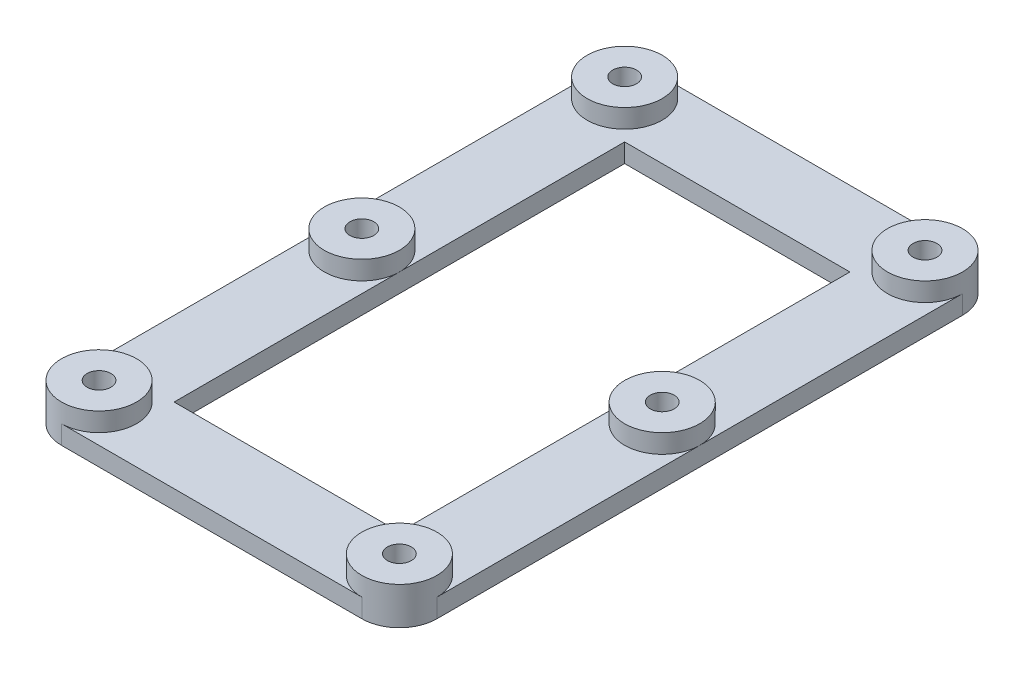
from build123d import *

# Parameters (mm, degrees)
SKETCH1_W              = 63.5
SKETCH1_H              = 101.6
BOSS_EXTRUDE1_DEPTH    = 6.35
FILLET1_R              = 6.35
F_10_32_TAPPED_HOLE1_D = 4.0386
SKETCH10_W             = 38.1
SKETCH10_H             = 76.2
CUT_EXTRUDE1_DEPTH     = 7.35
CUT_EXTRUDE2_DEPTH     = 3.175


with BuildPart() as part:
    # Sketch1 → Boss-Extrude1 (new body)
    with BuildSketch(Plane(origin=(0, 0, 0), x_dir=(1, 0, 0), z_dir=(0, 1, 0))):
        Rectangle(SKETCH1_W, SKETCH1_H)
    extrude(amount=BOSS_EXTRUDE1_DEPTH)

    # Fillet1
    fillet1_edges = [part.edges().sort_by_distance(p)[0] for p in [
        (-31.75, 3.175, -50.8),
        (31.75, 3.175, -50.8),
        (31.75, 3.175, 50.8),
        (-31.75, 3.175, 50.8),
    ]]
    fillet(fillet1_edges, radius=FILLET1_R)

    # #10-32 Tapped Hole1 (through all)
    with Locations(Plane(origin=(0, 6.35, 0), x_dir=(1, 0, 0), z_dir=(0, 1, 0))):
        with Locations((25.4, 44.45), (-25.4, 44.45), (-25.4, -44.45), (25.4, -44.45), (-25.4, 0), (25.4, 0)):
            Hole(F_10_32_TAPPED_HOLE1_D / 2)

    # Sketch10 → Cut-Extrude1 (cut, through all)
    with BuildSketch(Plane(origin=(0, 6.35, 0), x_dir=(1, 0, 0), z_dir=(0, 1, 0))):
        Rectangle(SKETCH10_W, SKETCH10_H)
    extrude(amount=-CUT_EXTRUDE1_DEPTH, mode=Mode.SUBTRACT)

    # Sketch11 → Cut-Extrude2 (cut)
    with BuildSketch(Plane(origin=(0, 6.35, 0), x_dir=(1, 0, 0), z_dir=(0, 1, 0))):
        with BuildLine():
            ThreePointArc((25.4, -50.8), (20.909871939, -39.959871939), (31.75, -44.45))
            Line((31.75, -44.45), (31.75, 0))
            ThreePointArc((31.75, 0), (25.4, -6.35), (19.05, 0))
            Line((19.05, 0), (19.05, -38.1))
            Line((19.05, -38.1), (-19.05, -38.1))
            Line((-19.05, -38.1), (-19.05, 0))
            ThreePointArc((-19.05, 0), (-25.4, -6.35), (-31.75, 0))
            Line((-31.75, 0), (-31.75, -44.45))
            ThreePointArc((-31.75, -44.45), (-20.909871939, -39.959871939), (-25.4, -50.8))
            Line((-25.4, -50.8), (25.4, -50.8))
        make_face()
        with BuildLine():
            ThreePointArc((19.05, 0), (25.4, 6.35), (31.75, 0))
            Line((31.75, 0), (31.75, 44.45))
            ThreePointArc((31.75, 44.45), (20.909871939, 39.959871939), (25.4, 50.8))
            Line((25.4, 50.8), (-25.4, 50.8))
            ThreePointArc((-25.4, 50.8), (-20.909871939, 39.959871939), (-31.75, 44.45))
            Line((-31.75, 44.45), (-31.75, 0))
            ThreePointArc((-31.75, 0), (-25.4, 6.35), (-19.05, 0))
            Line((-19.05, 0), (-19.05, 38.1))
            Line((-19.05, 38.1), (19.05, 38.1))
            Line((19.05, 38.1), (19.05, 0))
        make_face()
    extrude(amount=-CUT_EXTRUDE2_DEPTH, mode=Mode.SUBTRACT)


solid = part.part
